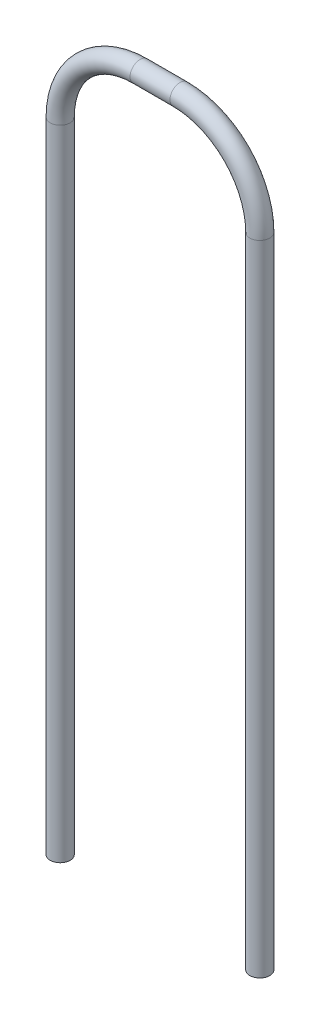
from build123d import *

# Parameters (mm, degrees)
SKETCH1_R = 0.25


with BuildPart() as part:
    # Sweep1: sweep along a path in Sketch2
    with BuildLine(Plane.XY) as sweep1_path:
        Line((-2.499404207, 0), (-2.499404207, 16))
        ThreePointArc((-2.499404207, 16), (-1.913617769, 17.414213562), (-0.499404207, 18))
        Line((-0.499404207, 18), (0.500595793, 18))
        ThreePointArc((0.500595793, 18), (1.914809356, 17.414213562), (2.500595793, 16))
        Line((2.500595793, 16), (2.500595793, 0))
    # Sketch1 → Sweep1 (sweep)
    with BuildSketch(Plane(origin=(0, 0, 0), x_dir=(1, 0, 0), z_dir=(0, 1, 0))):
        with Locations((-2.499404207, 0)):
            Circle(SKETCH1_R)
    sweep(path=sweep1_path.line)


solid = part.part
